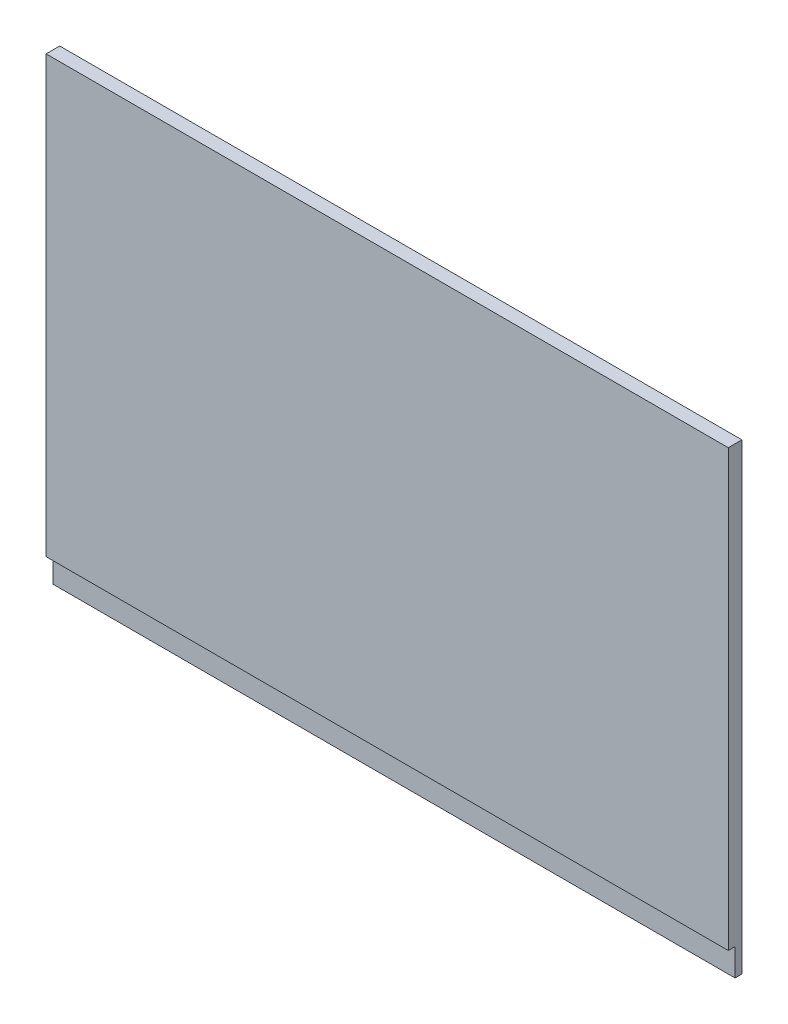
from build123d import *

# Parameters (mm, degrees)
SKETCH1_W           = 159.1564
SKETCH1_H           = 107.95
BOSS_EXTRUDE1_DEPTH = 3.175
SKETCH2_W           = 159.1564
SKETCH2_H           = 6.35
CUT_EXTRUDE1_DEPTH  = 1.5875


with BuildPart() as part:
    # Sketch1 → Boss-Extrude1 (new body)
    with BuildSketch(Plane.XY):
        with Locations((-79.5782, 53.975)):
            Rectangle(SKETCH1_W, SKETCH1_H)
    extrude(amount=BOSS_EXTRUDE1_DEPTH)

    # Sketch2 → Cut-Extrude1 (cut)
    with BuildSketch(Plane.XY.offset(3.175)):
        with Locations((-79.5782, 3.175)):
            Rectangle(SKETCH2_W, SKETCH2_H)
    extrude(amount=-CUT_EXTRUDE1_DEPTH, mode=Mode.SUBTRACT)


solid = part.part
